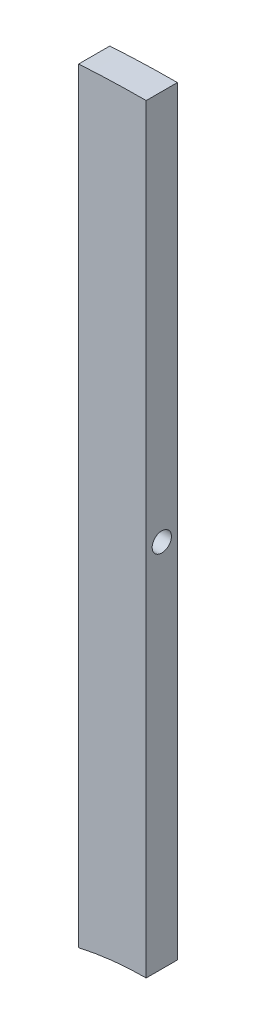
from build123d import *

# Parameters (mm, degrees)
SKETCH1_W           = 10
SKETCH1_H           = 5
EXTRUDE1_DEPTH      = 2.30625
SKETCH2_R           = 1.4224
EXTRUDE2_DEPTH      = 11
BOSS_EXTRUDE1_DEPTH = 4.6125


with BuildPart() as part:
    # Sketch1 → Extrude1 (new body, symmetric)
    with BuildSketch(Plane.XY):
        with Locations((-5, 0)):
            Rectangle(SKETCH1_W, SKETCH1_H)
    extrude(amount=EXTRUDE1_DEPTH, both=True)

    # Sketch2 → Extrude2 (cut, through all)
    with BuildSketch(Plane(origin=(0, 0, 0), x_dir=(0, 0, -1), z_dir=(1, 0, 0))):
        Circle(SKETCH2_R)
    extrude(amount=-EXTRUDE2_DEPTH, mode=Mode.SUBTRACT)

    # Sketch3 → Boss-Extrude1 (add)
    with BuildSketch(Plane(origin=(0, 0, -2.30625), x_dir=(-1, 0, 0), z_dir=(0, 0, -1))):
        with BuildLine():
            Line((10, 57.382622929), (10, 2.5))
            Line((10, 2.5), (0, 2.5))
            Line((0, 2.5), (0, 57.7))
            ThreePointArc((0, 57.7), (5.002517571, 57.620635762), (10, 57.382622929))
        make_face()
        with BuildLine():
            Line((0, -54.725), (0, -2.5))
            Line((0, -2.5), (10, -2.5))
            Line((10, -2.5), (10, -55.843170121))
            ThreePointArc((10, -55.843170121), (5.031160513, -55.005410893), (0, -54.725))
        make_face()
    extrude(amount=-BOSS_EXTRUDE1_DEPTH)


solid = part.part
